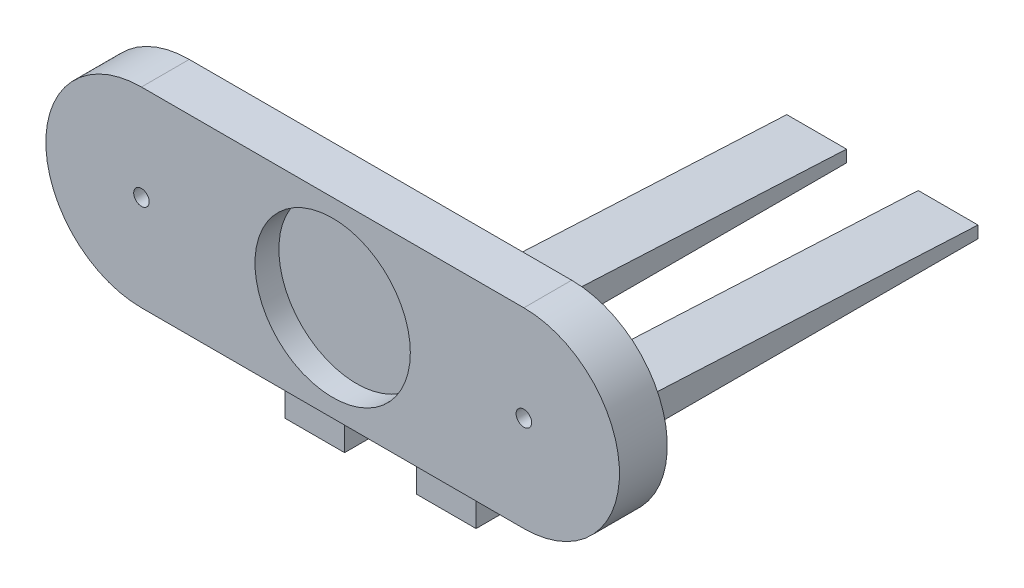
from build123d import *

# Parameters (mm, degrees)
EXTRUDE_1_DEPTH     = 20
SKETCH_4_R          = 32.5
CUT_EXTRUDE_4_DEPTH = 10
SKETCH_10_W         = 25
SKETCH_10_H         = 77.5
EXTRUDE_5_DEPTH     = 10
SKETCH_14_W         = 25
SKETCH_14_H         = 15
EXTRUDE_6_DEPTH     = 200
CUT_EXTRUDE_5_DEPTH = 161
SKETCH_16_R         = 3.25
CUT_EXTRUDE_6_DEPTH = 21
SKETCH_17_R         = 5.75
CUT_EXTRUDE_7_DEPTH = 10


with BuildPart() as part:
    # 스케치3 → 보스-돌출1 (new body)
    with BuildSketch(Plane.XY):
        with BuildLine():
            Line((-80, 40), (80, 40))
            ThreePointArc((80, 40), (120, 0), (80, -40))
            Line((80, -40), (-80, -40))
            ThreePointArc((-80, -40), (-120, 0), (-80, 40))
        make_face()
    extrude(amount=-EXTRUDE_1_DEPTH)

    # 스케치4 → 컷-돌출4 (cut)
    with BuildSketch(Plane.XY):
        Circle(SKETCH_4_R)
    extrude(amount=-CUT_EXTRUDE_4_DEPTH, mode=Mode.SUBTRACT)

    # 스케치10 → 보스-돌출5 (add)
    with BuildSketch(Plane(origin=(0, 0, -20), x_dir=(-1, 0, 0), z_dir=(0, 0, -1))):
        with Locations((-27.5, -31.25)):
            Rectangle(SKETCH_10_W, SKETCH_10_H)
        with Locations((27.5, -31.25)):
            Rectangle(SKETCH_10_W, SKETCH_10_H)
    extrude(amount=EXTRUDE_5_DEPTH)

    # 스케치14 → 보스-돌출6 (add)
    with BuildSketch(Plane(origin=(0, 0, -30), x_dir=(-1, 0, 0), z_dir=(0, 0, -1))):
        with Locations((-27.5, -62.5)):
            Rectangle(SKETCH_14_W, SKETCH_14_H)
        with Locations((27.5, -62.5)):
            Rectangle(SKETCH_14_W, SKETCH_14_H)
    extrude(amount=EXTRUDE_6_DEPTH)

    # 스케치15 → 컷-돌출5 (cut, through all)
    with BuildSketch(Plane(origin=(40, 0, 0), x_dir=(0, 0, -1), z_dir=(1, 0, 0))):
        Polygon((30, -55), (230, -65), (230, -55), align=None)
    extrude(amount=-CUT_EXTRUDE_5_DEPTH, mode=Mode.SUBTRACT)

    # 스케치16 → 컷-돌출6 (cut, through all)
    with BuildSketch(Plane(origin=(0, 0, -20), x_dir=(-1, 0, 0), z_dir=(0, 0, -1))):
        with Locations((-80, 0)):
            Circle(SKETCH_16_R)
        with Locations((80, 0)):
            Circle(SKETCH_16_R)
    extrude(amount=-CUT_EXTRUDE_6_DEPTH, mode=Mode.SUBTRACT)

    # 스케치17 → 컷-돌출7 (cut)
    with BuildSketch(Plane(origin=(0, 0, -20), x_dir=(-1, 0, 0), z_dir=(0, 0, -1))):
        with Locations((-80, 0)):
            Circle(SKETCH_17_R)
        with Locations((80, 0)):
            Circle(SKETCH_17_R)
    extrude(amount=-CUT_EXTRUDE_7_DEPTH, mode=Mode.SUBTRACT)


solid = part.part
